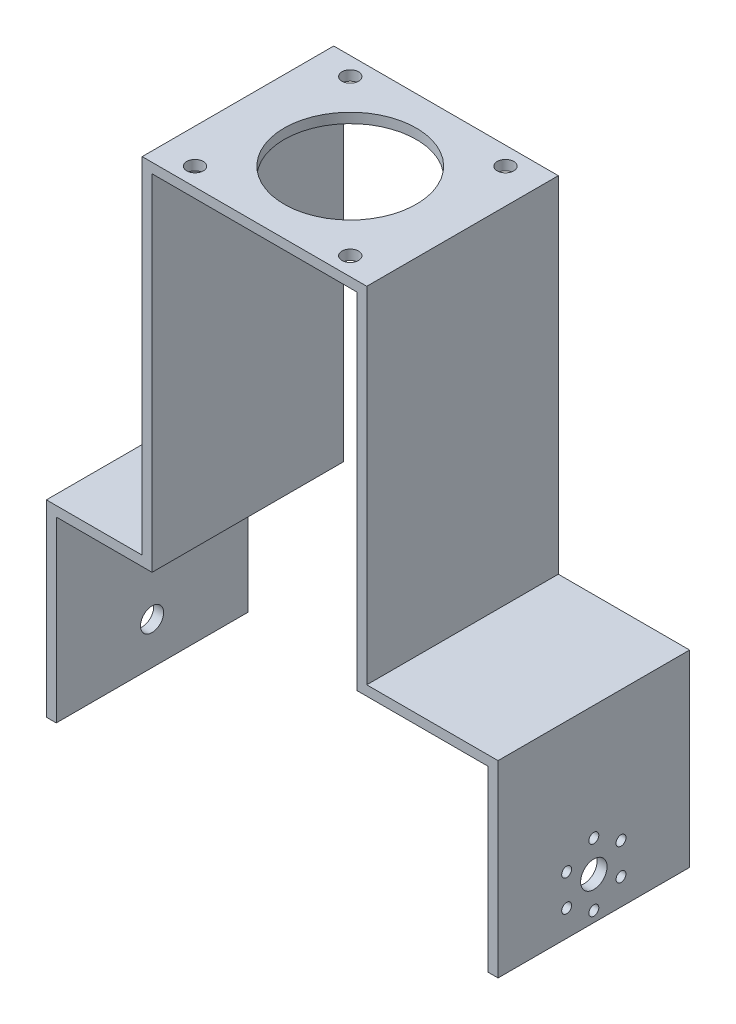
from build123d import *

# Parameters (mm, degrees)
BOSS_EXTRUDE1_DEPTH = 58
SKETCH5_R           = 3.5
CUT_EXTRUDE3_DEPTH  = 58
SKETCH15_R          = 4
CUT_EXTRUDE4_DEPTH  = 10
SKETCH16_R          = 1.5
CUT_EXTRUDE5_DEPTH  = 10
SKETCH17_R          = 20
SKETCH17_R_2        = 2.5
CUT_EXTRUDE6_DEPTH  = 10


with BuildPart() as part:
    # Sketch2 → Boss-Extrude1 (new body)
    with BuildSketch(Plane.XY):
        Polygon((2, 51.896715462), (36, 51.896715462), (36, -52.603284538), (75.75, -52.603284538), (75.75, -109.603284538), (72.75, -109.603284538), (72.75, -55.603284538), (33, -55.603284538), (33, 48.896715462), (2, 48.896715462), (-29, 48.896715462), (-29, -55.603284538), (-58, -55.603284538), (-58, -109.603284538), (-61, -109.603284538), (-61, -52.603284538), (-32, -52.603284538), (-32, 51.896715462), align=None)
    extrude(amount=BOSS_EXTRUDE1_DEPTH)

    # Sketch5 → Cut-Extrude3 (cut)
    with BuildSketch(Plane.ZY.offset(61)):
        with Locations((29, -96.903284538)):
            Circle(SKETCH5_R)
    extrude(amount=-CUT_EXTRUDE3_DEPTH, mode=Mode.SUBTRACT)

    # Sketch15 → Cut-Extrude4 (cut)
    with BuildSketch(Plane(origin=(75.75, 0, 0), x_dir=(0, 0, -1), z_dir=(1, 0, 0))):
        with Locations((-29, -96.902439923)):
            Circle(SKETCH15_R)
    extrude(amount=-CUT_EXTRUDE4_DEPTH, mode=Mode.SUBTRACT)

    # Sketch16 → Cut-Extrude5 (cut)
    with BuildSketch(Plane(origin=(75.75, 0, 0), x_dir=(0, 0, -1), z_dir=(1, 0, 0))):
        with Locations((-29, -87.402439923)):
            Circle(SKETCH16_R)
        with Locations((-20.772758664, -92.152439923)):
            Circle(SKETCH16_R)
        with Locations((-20.772758664, -101.652439923)):
            Circle(SKETCH16_R)
        with Locations((-29, -106.402439923)):
            Circle(SKETCH16_R)
        with Locations((-37.227241336, -101.652439923)):
            Circle(SKETCH16_R)
        with Locations((-37.227241336, -92.152439923)):
            Circle(SKETCH16_R)
    extrude(amount=-CUT_EXTRUDE5_DEPTH, mode=Mode.SUBTRACT)

    # Sketch17 → Cut-Extrude6 (cut)
    with BuildSketch(Plane(origin=(0, 51.896715462, 0), x_dir=(1, 0, 0), z_dir=(0, 1, 0))):
        with Locations((2, -29)):
            Circle(SKETCH17_R)
        with Locations((-21.5, -5.5)):
            Circle(SKETCH17_R_2)
        with Locations((25.5, -5.5)):
            Circle(SKETCH17_R_2)
        with Locations((25.5, -52.5)):
            Circle(SKETCH17_R_2)
        with Locations((-21.5, -52.5)):
            Circle(SKETCH17_R_2)
    extrude(amount=-CUT_EXTRUDE6_DEPTH, mode=Mode.SUBTRACT)


solid = part.part
